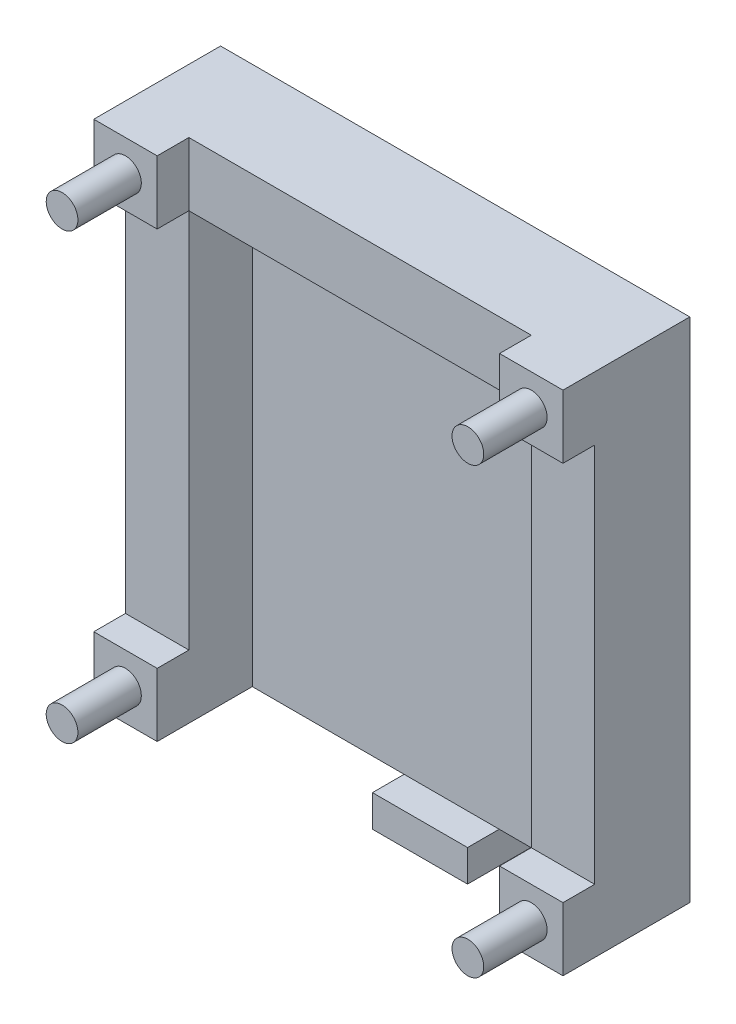
from build123d import *

# Parameters (mm, degrees)
CROQUIS1_W               = 54
CROQUIS1_H               = 70
SALIENTE_EXTRUIR1_DEPTH  = 5
CROQUIS4_W               = 54
CROQUIS4_H               = 10
SALIENTE_EXTRUIR5_DEPTH  = 15
CROQUIS5_W               = 10
CROQUIS5_H               = 10
SALIENTE_EXTRUIR6_DEPTH  = 20
CROQUIS6_W               = 15
CROQUIS6_H               = 5
SALIENTE_EXTRUIR7_DEPTH  = 10
CROQUIS8_W               = 10
CROQUIS8_H               = 60
SALIENTE_EXTRUIR9_DEPTH  = 15
CROQUIS9_R               = 2.5
SALIENTE_EXTRUIR10_DEPTH = 10
CROQUIS11_R              = 2.55
CORTAR_EXTRUIR1_DEPTH    = 10


with BuildPart() as part:
    # Croquis1 → Saliente-Extruir1 (new body)
    with BuildSketch(Plane.XY):
        with Locations((28.400543811, 1.50863747)):
            Rectangle(CROQUIS1_W, CROQUIS1_H)
    extrude(amount=SALIENTE_EXTRUIR1_DEPTH)

    # Croquis4 → Saliente-Extruir5 (add)
    with BuildSketch(Plane(origin=(0, 0, 0), x_dir=(-1, 0, 0), z_dir=(0, 0, -1))):
        with Locations((-28.400543811, 41.50863747)):
            Rectangle(CROQUIS4_W, CROQUIS4_H)
    extrude(amount=-SALIENTE_EXTRUIR5_DEPTH)

    # Croquis5 → Saliente-Extruir6 (add)
    with BuildSketch(Plane(origin=(0, 0, 0), x_dir=(-1, 0, 0), z_dir=(0, 0, -1))):
        with Locations((-60.400543811, 41.50863747)):
            Rectangle(CROQUIS5_W, CROQUIS5_H)
        with Locations((-60.400543811, -28.49136253)):
            Rectangle(CROQUIS5_W, CROQUIS5_H)
        with Locations((3.599456189, -28.49136253)):
            Rectangle(CROQUIS5_W, CROQUIS5_H)
        with Locations((3.599456189, 41.50863747)):
            Rectangle(CROQUIS5_W, CROQUIS5_H)
    extrude(amount=-SALIENTE_EXTRUIR6_DEPTH)

    # Croquis8 → Saliente-Extruir9 (add)
    with BuildSketch(Plane(origin=(0, 0, 0), x_dir=(-1, 0, 0), z_dir=(0, 0, -1))):
        with Locations((-60.400543811, 6.50863747)):
            Rectangle(CROQUIS8_W, CROQUIS8_H)
        with Locations((3.599456189, 6.50863747)):
            Rectangle(CROQUIS8_W, CROQUIS8_H)
    extrude(amount=-SALIENTE_EXTRUIR9_DEPTH)

    # Croquis9 → Saliente-Extruir10 (add)
    with BuildSketch(Plane.XY.offset(20)):
        with BuildLine():
            ThreePointArc((-1.099456189, 41.50863747), (-3.599456189, 44.00863747), (-6.099456189, 41.50863747))
            Line((-6.099456189, 41.50863747), (-1.099456189, 41.50863747))
        make_face()
        with BuildLine():
            Line((-1.099456189, 41.50863747), (-6.099456189, 41.50863747))
            ThreePointArc((-6.099456189, 41.50863747), (-3.599456189, 39.00863747), (-1.099456189, 41.50863747))
        make_face()
        with Locations((60.400543811, 41.50863747)):
            Circle(CROQUIS9_R)
        with Locations((60.400543811, -28.49136253)):
            Circle(CROQUIS9_R)
        with Locations((-3.599456189, -28.49136253)):
            Circle(CROQUIS9_R)
    extrude(amount=SALIENTE_EXTRUIR10_DEPTH)

    # Croquis11 → Cortar-Extruir1 (cut)
    with BuildSketch(Plane(origin=(0, 0, 0), x_dir=(-1, 0, 0), z_dir=(0, 0, -1))):
        with BuildLine():
            ThreePointArc((-57.850543811, 41.50863747), (-60.400543811, 44.05863747), (-62.950543811, 41.50863747))
            Line((-62.950543811, 41.50863747), (-60.400543811, 41.50863747))
            Line((-60.400543811, 41.50863747), (-57.850543811, 41.50863747))
        make_face()
        with BuildLine():
            Line((-60.400543811, 41.50863747), (-62.950543811, 41.50863747))
            ThreePointArc((-62.950543811, 41.50863747), (-60.400543811, 38.95863747), (-57.850543811, 41.50863747))
            Line((-57.850543811, 41.50863747), (-60.400543811, 41.50863747))
        make_face()
        with BuildLine():
            ThreePointArc((6.149456189, 41.50863747), (3.599456189, 44.05863747), (1.049456189, 41.50863747))
            Line((1.049456189, 41.50863747), (6.149456189, 41.50863747))
        make_face()
        with BuildLine():
            Line((6.149456189, 41.50863747), (1.049456189, 41.50863747))
            ThreePointArc((1.049456189, 41.50863747), (3.599456189, 38.95863747), (6.149456189, 41.50863747))
        make_face()
        with Locations((3.599456189, -28.49136253)):
            Circle(CROQUIS11_R)
        with Locations((-60.400543811, -28.49136253)):
            Circle(CROQUIS11_R)
    extrude(amount=-CORTAR_EXTRUIR1_DEPTH, mode=Mode.SUBTRACT)


with BuildPart() as body_2:
    # Croquis6 → Saliente-Extruir7 (new body)
    with BuildSketch(Plane(origin=(0, 0, 0), x_dir=(-1, 0, 0), z_dir=(0, 0, -1))):
        with Locations((-32.848967284, -35.99136253)):
            Rectangle(CROQUIS6_W, CROQUIS6_H)
    extrude(amount=-SALIENTE_EXTRUIR7_DEPTH)


solid = Compound([part.part, body_2.part])
